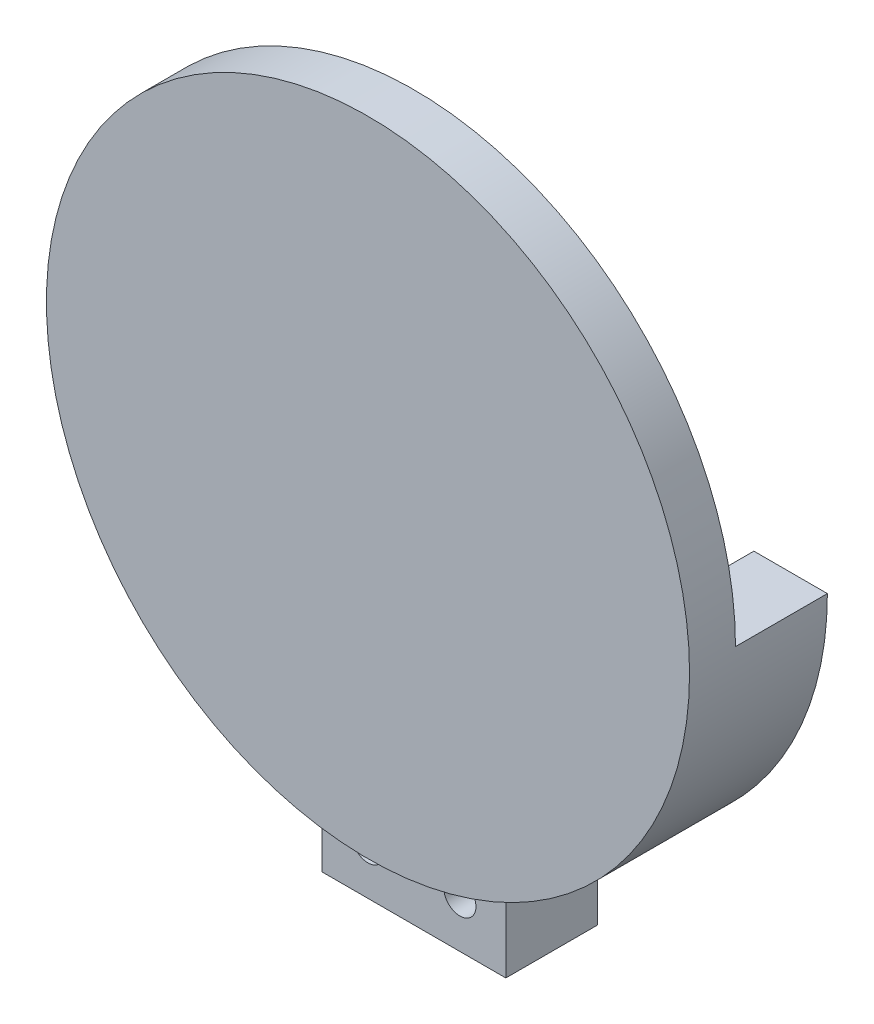
from build123d import *

# Parameters (mm, degrees)
SKETCH1_R               = 4.1
BOSS_EXTRUDE1_DEPTH     = 7
SKETCH2_R               = 6.25
BOSS_EXTRUDE2_DEPTH     = 2
SKETCH3_R               = 35
BOSS_EXTRUDE3_DEPTH     = 5
SKETCH4_R               = 25
BOSS_EXTRUDE4_DEPTH     = 5
SKETCH5_R               = 30
BOSS_EXTRUDE5_DEPTH     = 2
FILLET1_R               = 2
FILLET2_R               = 2
SKETCH6_R               = 1.5
CUT_EXTRUDE1_DEPTH      = 36
CUT_EXTRUDE1_DEPTH_BACK = 36
BOSS_EXTRUDE6_DEPTH     = 10
SKETCH9_R               = 1.75
CUT_EXTRUDE2_DEPTH      = 10
SKETCH10_R              = 52.509710967
CUT_EXTRUDE3_DEPTH      = 40


with BuildPart() as part:
    # Sketch1 → Boss-Extrude1 (new body)
    with BuildSketch(Plane.XY):
        Circle(SKETCH1_R)
    extrude(amount=BOSS_EXTRUDE1_DEPTH)

    # Sketch2 → Boss-Extrude2 (add)
    with BuildSketch(Plane.XY.offset(7)):
        Circle(SKETCH2_R)
    extrude(amount=BOSS_EXTRUDE2_DEPTH)

    # Sketch3 → Boss-Extrude3 (add)
    with BuildSketch(Plane.XY.offset(9)):
        Circle(SKETCH3_R)
    extrude(amount=BOSS_EXTRUDE3_DEPTH)

    # Sketch4 → Boss-Extrude4 (add)
    with BuildSketch(Plane.XY.offset(14)):
        Circle(SKETCH4_R)
    extrude(amount=BOSS_EXTRUDE4_DEPTH)

    # Sketch5 → Boss-Extrude5 (add)
    with BuildSketch(Plane.XY.offset(19)):
        Circle(SKETCH5_R)
    extrude(amount=BOSS_EXTRUDE5_DEPTH)

    # Fillet1
    fillet1_edges = [part.edges().sort_by_distance(p)[0] for p in [
        (-25, 0, 19),
    ]]
    fillet(fillet1_edges, radius=FILLET1_R)

    # Fillet2
    fillet2_edges = [part.edges().sort_by_distance(p)[0] for p in [
        (-25, 0, 14),
    ]]
    fillet(fillet2_edges, radius=FILLET2_R)

    # Sketch6 → Cut-Extrude1 (cut, two sides)
    with BuildSketch(Plane(origin=(0, 0, 0), x_dir=(1, 0, 0), z_dir=(0, 1, 0))) as cut_extrude1_sk:
        with Locations((0.008646323, -16.5)):
            Circle(SKETCH6_R)
    extrude(amount=CUT_EXTRUDE1_DEPTH, mode=Mode.SUBTRACT)
    extrude(cut_extrude1_sk.sketch, amount=-CUT_EXTRUDE1_DEPTH_BACK, mode=Mode.SUBTRACT)

    # Sketch7 → Boss-Extrude6 (add)
    with BuildSketch(Plane(origin=(0, 0, 9), x_dir=(-1, 0, 0), z_dir=(0, 0, -1))):
        with BuildLine():
            Line((10, -33.541019662), (10, -33.735334875))
            Line((10, -33.735334875), (10, -43.735334875))
            Line((10, -43.735334875), (-10, -43.735334875))
            Line((-10, -43.735334875), (-10, -33.735334875))
            Line((-10, -33.735334875), (-10, -33.541019662))
            ThreePointArc((-10, -33.541019662), (-28.062430401, -20.916500663), (-35, 0))
            Line((-35, 0), (-27, 0))
            ThreePointArc((-27, 0), (-15.149257408, -22.349496639), (10, -25.079872408))
            Line((10, -25.079872408), (10, -33.541019662))
        make_face()
    extrude(amount=BOSS_EXTRUDE6_DEPTH)

    # Sketch9 → Cut-Extrude2 (cut)
    with BuildSketch(Plane(origin=(0, 0, -1), x_dir=(-1, 0, 0), z_dir=(0, 0, -1))):
        with Locations((5, -38.638177269)):
            Circle(SKETCH9_R)
        with Locations((-5, -38.638177269)):
            Circle(SKETCH9_R)
    extrude(amount=-CUT_EXTRUDE2_DEPTH, mode=Mode.SUBTRACT)

    # Sketch10 → Cut-Extrude3 (cut)
    with BuildSketch(Plane.XY.offset(14)):
        Circle(SKETCH10_R)
    extrude(amount=CUT_EXTRUDE3_DEPTH, mode=Mode.SUBTRACT)


solid = part.part
